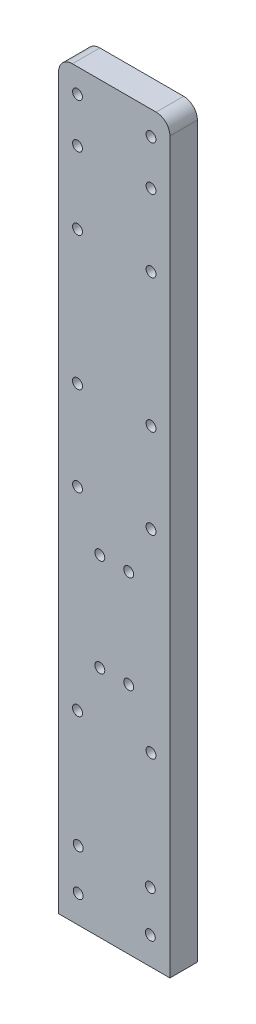
from build123d import *

# Parameters (mm, degrees)
SKETCH1_W           = 16.2
SKETCH1_H           = 108.14
SKETCH1_R           = 0.72
BOSS_EXTRUDE1_DEPTH = 4
FILLET1_R           = 2


with BuildPart() as part:
    # Sketch1 → Boss-Extrude1 (new body)
    with BuildSketch(Plane.XY):
        with Locations((8.1, 54.07)):
            Rectangle(SKETCH1_W, SKETCH1_H)
        with Locations((13.45, 55.21)):
            Circle(SKETCH1_R, mode=Mode.SUBTRACT)
        with Locations((10.2, 48.21)):
            Circle(SKETCH1_R, mode=Mode.SUBTRACT)
        with Locations((13.45, 104.66)):
            Circle(SKETCH1_R, mode=Mode.SUBTRACT)
        with Locations((2.75, 98.16)):
            Circle(SKETCH1_R, mode=Mode.SUBTRACT)
        with Locations((6, 48.21)):
            Circle(SKETCH1_R, mode=Mode.SUBTRACT)
        with Locations((2.75, 27)):
            Circle(SKETCH1_R, mode=Mode.SUBTRACT)
        with Locations((2.75, 87.66)):
            Circle(SKETCH1_R, mode=Mode.SUBTRACT)
        with Locations((2.75, 55.21)):
            Circle(SKETCH1_R, mode=Mode.SUBTRACT)
        with Locations((13.45, 87.66)):
            Circle(SKETCH1_R, mode=Mode.SUBTRACT)
        with Locations((13.45, 98.16)):
            Circle(SKETCH1_R, mode=Mode.SUBTRACT)
        with Locations((13.45, 68.21)):
            Circle(SKETCH1_R, mode=Mode.SUBTRACT)
        with Locations((6, 34)):
            Circle(SKETCH1_R, mode=Mode.SUBTRACT)
        with Locations((2.75, 104.66)):
            Circle(SKETCH1_R, mode=Mode.SUBTRACT)
        with Locations((10.2, 34)):
            Circle(SKETCH1_R, mode=Mode.SUBTRACT)
        with Locations((2.75, 68.21)):
            Circle(SKETCH1_R, mode=Mode.SUBTRACT)
        with Locations((13.45, 27)):
            Circle(SKETCH1_R, mode=Mode.SUBTRACT)
        with Locations((2.85, 10)):
            Circle(SKETCH1_R, mode=Mode.SUBTRACT)
        with Locations((13.35, 10)):
            Circle(SKETCH1_R, mode=Mode.SUBTRACT)
        with Locations((13.35, 4)):
            Circle(SKETCH1_R, mode=Mode.SUBTRACT)
        with Locations((2.85, 4)):
            Circle(SKETCH1_R, mode=Mode.SUBTRACT)
    extrude(amount=BOSS_EXTRUDE1_DEPTH)

    # Fillet1
    fillet1_edges = [part.edges().sort_by_distance(p)[0] for p in [
        (0, 108.14, 2),
        (16.2, 108.14, 2),
    ]]
    fillet(fillet1_edges, radius=FILLET1_R)


solid = part.part
